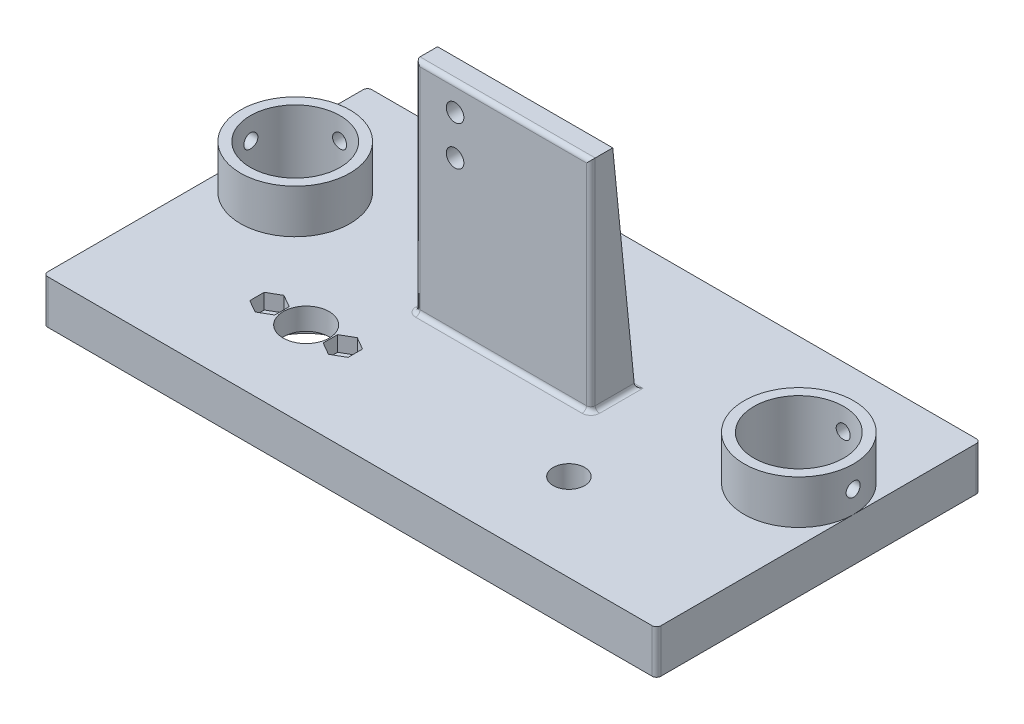
from build123d import *

# Parameters (mm, degrees)
SALIENTE_EXTRUIR1_DEPTH = 10
CROQUIS3_R              = 5.25
CROQUIS3_R_2            = 3.6
CROQUIS3_R_3            = 1.6
CORTAR_EXTRUIR1_DEPTH   = 11
CORTAR_EXTRUIR2_DEPTH   = 3.5
CROQUIS5_R              = 11.75
CORTAR_EXTRUIR3_DEPTH   = 5
CROQUIS8_W              = 90
CROQUIS8_H              = 29
SALIENTE_EXTRUIR2_DEPTH = 10
CROQUIS9_W              = 25
CROQUIS9_H              = 25
SALIENTE_EXTRUIR4_DEPTH = 10
CROQUIS13_R             = 12.5
SALIENTE_EXTRUIR5_DEPTH = 10
CROQUIS15_R             = 10.25
CORTAR_EXTRUIR5_DEPTH   = 20
CROQUIS16_R             = 1.6
CORTAR_EXTRUIR6_DEPTH   = 10
CROQUIS17_W             = 25
CROQUIS17_H             = 16.5
CROQUIS17_H_2           = 32.5
SALIENTE_EXTRUIR6_DEPTH = 10
CORTAR_EXTRUIR10_START  = 60
CROQUIS19_R             = 1.6
CORTAR_EXTRUIR10_DEPTH  = 11.0000001
SALIENTE_EXTRUIR7_DEPTH = 50
CROQUIS21_R             = 2
CORTAR_EXTRUIR11_DEPTH  = 40
CORTAR_EXTRUIR12_DEPTH  = 40
REDONDEO2_R             = 1
REDONDEO3_R             = 1


with BuildPart() as part:
    # Croquis1 → Saliente-Extruir1 (new body)
    with BuildSketch(Plane(origin=(0, 0, 0), x_dir=(1, 0, 0), z_dir=(0, 1, 0))):
        Polygon((-45, -22.5), (45, -22.5), (45, 22.5), (0, 22.5), (-45, 22.5), align=None)
    extrude(amount=SALIENTE_EXTRUIR1_DEPTH)

    # Croquis3 → Cortar-Extruir1 (cut, through all)
    with BuildSketch(Plane(origin=(0, 10, 0), x_dir=(1, 0, 0), z_dir=(0, 1, 0))):
        with Locations((-30, -2.5)):
            Circle(CROQUIS3_R)
        with Locations((30, -2.5)):
            Circle(CROQUIS3_R_2)
        with Locations((-38.375, -2.5)):
            Circle(CROQUIS3_R_3)
        with Locations((-21.625, -2.5)):
            Circle(CROQUIS3_R_3)
    extrude(amount=-CORTAR_EXTRUIR1_DEPTH, mode=Mode.SUBTRACT)

    # Croquis4 → Cortar-Extruir2 (cut)
    with BuildSketch(Plane(origin=(0, 10, 0), x_dir=(1, 0, 0), z_dir=(0, 1, 0))):
        Polygon((-38.375, 0.790896534), (-41.225, -0.854551733), (-41.225, -4.145448267), (-38.375, -5.790896534), (-35.525, -4.145448267), (-35.525, -0.854551733), align=None)
        Polygon((-21.625, 0.790896534), (-24.475, -0.854551733), (-24.475, -4.145448267), (-21.625, -5.790896534), (-18.775, -4.145448267), (-18.775, -0.854551733), align=None)
    extrude(amount=-CORTAR_EXTRUIR2_DEPTH, mode=Mode.SUBTRACT)

    # Croquis5 → Cortar-Extruir3 (cut)
    with BuildSketch(Plane.XZ):
        with Locations((-30, 2.5)):
            Circle(CROQUIS5_R)
    extrude(amount=-CORTAR_EXTRUIR3_DEPTH, mode=Mode.SUBTRACT)

    # Croquis8 → Saliente-Extruir2 (add)
    with BuildSketch(Plane(origin=(0, 10, 0), x_dir=(1, 0, 0), z_dir=(0, 1, 0))):
        with Locations((0, 37)):
            Rectangle(CROQUIS8_W, CROQUIS8_H)
    extrude(amount=-SALIENTE_EXTRUIR2_DEPTH)

    # Croquis9 → Saliente-Extruir4 (add)
    with BuildSketch(Plane(origin=(0, 0, 0), x_dir=(1, 0, 0), z_dir=(0, 1, 0))):
        with Locations((-57.5, 22.5)):
            Rectangle(CROQUIS9_W, CROQUIS9_H)
        with Locations((57.5, 22.5)):
            Rectangle(CROQUIS9_W, CROQUIS9_H)
    extrude(amount=SALIENTE_EXTRUIR4_DEPTH)

    # Croquis13 → Saliente-Extruir5 (add)
    with BuildSketch(Plane(origin=(0, 10, 0), x_dir=(1, 0, 0), z_dir=(0, 1, 0))):
        with Locations((-57.5, 22.5)):
            Circle(CROQUIS13_R)
        with Locations((57.5, 22.5)):
            Circle(CROQUIS13_R)
    extrude(amount=SALIENTE_EXTRUIR5_DEPTH)

    # Croquis15 → Cortar-Extruir5 (cut)
    with BuildSketch(Plane(origin=(0, 20, 0), x_dir=(1, 0, 0), z_dir=(0, 1, 0))):
        with Locations((-57.5, 22.5)):
            Circle(CROQUIS15_R)
        with Locations((57.5, 22.5)):
            Circle(CROQUIS15_R)
    extrude(amount=-CORTAR_EXTRUIR5_DEPTH, mode=Mode.SUBTRACT)

    # Croquis16 → Cortar-Extruir6 (cut)
    with BuildSketch(Plane(origin=(0, 0, -35), x_dir=(-1, 0, 0), z_dir=(0, 0, -1))):
        with Locations((-57.5, 15)):
            Circle(CROQUIS16_R)
        with Locations((57.5, 15)):
            Circle(CROQUIS16_R)
    extrude(amount=-CORTAR_EXTRUIR6_DEPTH, mode=Mode.SUBTRACT)

    # Croquis17 → Saliente-Extruir6 (add)
    with BuildSketch(Plane(origin=(0, 0, 0), x_dir=(1, 0, 0), z_dir=(0, 1, 0))):
        with Locations((57.5, 43.25)):
            Rectangle(CROQUIS17_W, CROQUIS17_H)
        with Locations((57.5, -6.25)):
            Rectangle(CROQUIS17_W, CROQUIS17_H_2)
        with Locations((-57.5, 43.25)):
            Rectangle(CROQUIS17_W, CROQUIS17_H)
        with Locations((-57.5, -6.25)):
            Rectangle(CROQUIS17_W, CROQUIS17_H_2)
    extrude(amount=SALIENTE_EXTRUIR6_DEPTH)

    # Croquis19 → Cortar-Extruir10 (cut, through all)
    with BuildSketch(Plane(origin=(0, 0, 0), x_dir=(0, 0, -1), z_dir=(1, 0, 0)).offset(CORTAR_EXTRUIR10_START)):
        with Locations((22.5, 15)):
            Circle(CROQUIS19_R)
    cortar_extruir10 = extrude(amount=CORTAR_EXTRUIR10_DEPTH, mode=Mode.SUBTRACT)

    # Simetría1: Cortar-Extruir10 across plane
    add(cortar_extruir10.mirror(Plane(origin=(0, 0, 0), x_dir=(0, 0, 1), z_dir=(1, 0, 0))), mode=Mode.SUBTRACT)

    # Croquis20 → Saliente-Extruir7 (add)
    with BuildSketch(Plane(origin=(0, 10, 0), x_dir=(1, 0, 0), z_dir=(0, 1, 0))):
        Polygon((-20, 22.5), (-17, 22.5), (-17, 17.5), (17, 17.5), (17, 22.5), (20, 22.5), (20, 12.5), (-20, 12.5), align=None)
    extrude(amount=SALIENTE_EXTRUIR7_DEPTH)

    # Croquis21 → Cortar-Extruir11 (cut, through all)
    with BuildSketch(Plane.XY.offset(-12.5)):
        with Locations((-11, 54)):
            Circle(CROQUIS21_R)
        with Locations((-11, 45)):
            Circle(CROQUIS21_R)
    extrude(amount=-CORTAR_EXTRUIR11_DEPTH, mode=Mode.SUBTRACT)

    # Croquis22 → Cortar-Extruir12 (cut)
    with BuildSketch(Plane(origin=(20, 0, 0), x_dir=(0, 0, -1), z_dir=(1, 0, 0))):
        Polygon((17.5, 60), (22.5, 10), (22.5, 60), align=None)
    extrude(amount=-CORTAR_EXTRUIR12_DEPTH, mode=Mode.SUBTRACT)

    # Redondeo2
    redondeo2_edges = [part.edges().sort_by_distance(p)[0] for p in [
        (-70, 5, -51.5),
        (-70, 5, 22.5),
        (70, 5, -51.5),
        (70, 5, 22.5),
    ]]
    fillet(redondeo2_edges, radius=REDONDEO2_R)

    # Redondeo3
    redondeo3_edges = [part.edges().sort_by_distance(p)[0] for p in [
        (-20, 10, -17.5),
        (0, 10, -12.5),
        (-20, 35, -12.5),
        (20, 10, -17.5),
        (20, 35, -12.5),
        (18.5, 10, -22.5),
        (17, 10, -20),
        (0, 10, -17.5),
        (17, 35, -17.5),
        (-17, 10, -20),
        (-17, 35, -17.5),
        (-18.5, 10, -22.5),
        (0, 60, -12.5),
    ]]
    fillet(redondeo3_edges, radius=REDONDEO3_R)


solid = part.part
